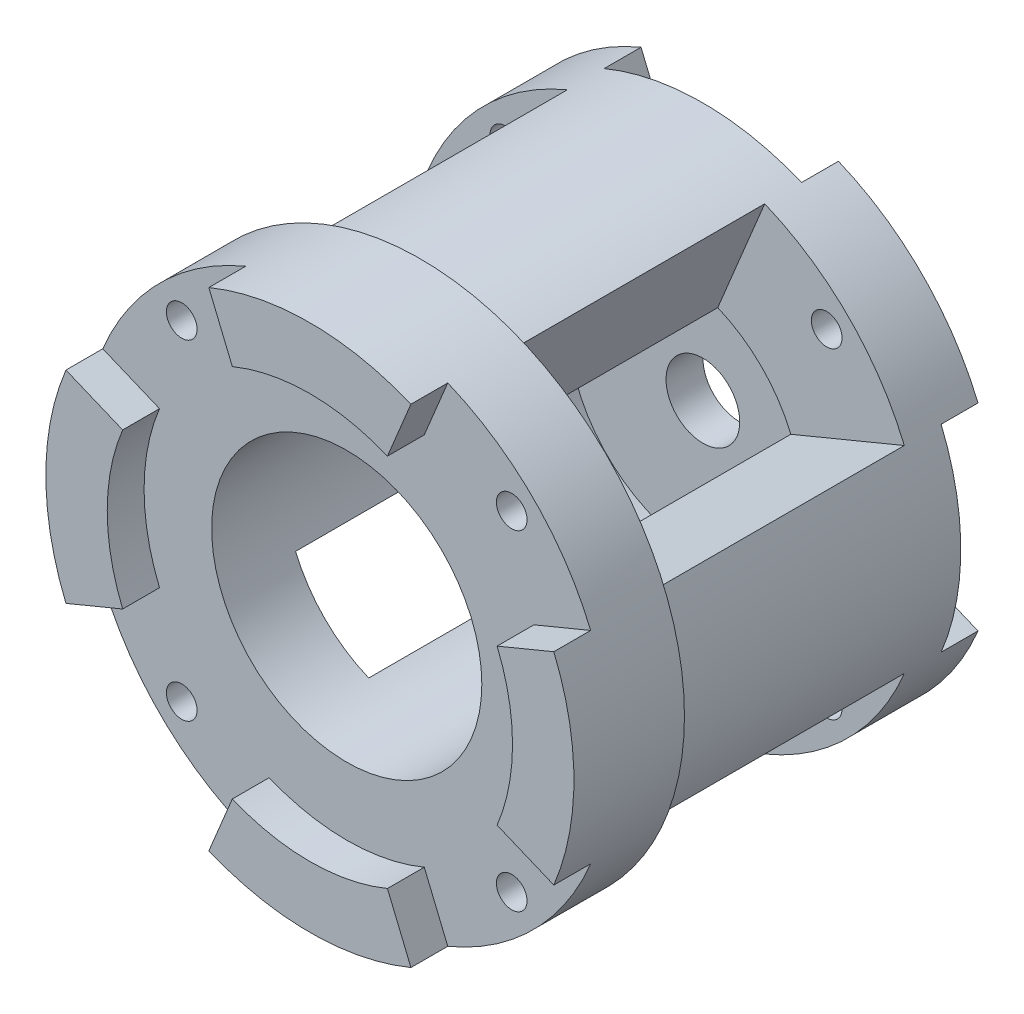
from build123d import *
from build123d.topology import SkipClean

# Parameters (mm, degrees)
SKETCH1_R           = 21
SKETCH1_R_2         = 1.25
SKETCH1_R_3         = 11
BOSS_EXTRUDE1_DEPTH = 3
BOSS_EXTRUDE2_START = -3
SKETCH1_3_R         = 3
SKETCH1_3_R_2       = 1.25
BOSS_EXTRUDE2_DEPTH = 3
BOSS_EXTRUDE3_DEPTH = 20
SKETCH5_R           = 21.5
SKETCH5_R_2         = 11
SKETCH5_R_3         = 1.25
BOSS_EXTRUDE4_DEPTH = 6
BOSS_EXTRUDE5_DEPTH = 3


with BuildPart() as part:
    # Sketch1 → Boss-Extrude1 (new body)
    with BuildSketch(Plane.XY):
        Circle(SKETCH1_R)
        with Locations((-13.081475452, -13.081475452)):
            Circle(SKETCH1_R_2, mode=Mode.SUBTRACT)
        with Locations((13.081475452, -13.081475452)):
            Circle(SKETCH1_R_2, mode=Mode.SUBTRACT)
        with Locations((-13.081475452, 13.081475452)):
            Circle(SKETCH1_R_2, mode=Mode.SUBTRACT)
        Circle(SKETCH1_R_3, mode=Mode.SUBTRACT)
        with Locations((13.081475452, 13.081475452)):
            Circle(SKETCH1_R_2, mode=Mode.SUBTRACT)
    extrude(amount=BOSS_EXTRUDE1_DEPTH)

    # Sketch1_3 → Boss-Extrude2 (add)
    with BuildSketch(Plane.XY.offset(BOSS_EXTRUDE2_START)):
        with BuildLine():
            ThreePointArc((0, 16), (-3.121445152, 15.692564486), (-6.122934918, 14.78207252))
            Line((-6.122934918, 14.78207252), (-8.03635208, 19.401470183))
            ThreePointArc((-8.03635208, 19.401470183), (-14.849242405, 14.849242405), (-19.401470183, 8.03635208))
            Line((-19.401470183, 8.03635208), (-14.78207252, 6.122934918))
            ThreePointArc((-14.78207252, 6.122934918), (-16, 0), (-14.78207252, -6.122934918))
            Line((-14.78207252, -6.122934918), (-19.401470183, -8.03635208))
            ThreePointArc((-19.401470183, -8.03635208), (-14.849242405, -14.849242405), (-8.03635208, -19.401470183))
            Line((-8.03635208, -19.401470183), (-6.122934918, -14.78207252))
            ThreePointArc((-6.122934918, -14.78207252), (0, -16), (6.122934918, -14.78207252))
            Line((6.122934918, -14.78207252), (8.03635208, -19.401470183))
            ThreePointArc((8.03635208, -19.401470183), (14.849242405, -14.849242405), (19.401470183, -8.03635208))
            Line((19.401470183, -8.03635208), (14.78207252, -6.122934918))
            ThreePointArc((14.78207252, -6.122934918), (16, 0), (14.78207252, 6.122934918))
            Line((14.78207252, 6.122934918), (19.401470183, 8.03635208))
            ThreePointArc((19.401470183, 8.03635208), (14.849242405, 14.849242405), (8.03635208, 19.401470183))
            Line((8.03635208, 19.401470183), (6.122934918, 14.78207252))
            ThreePointArc((6.122934918, 14.78207252), (3.121445152, 15.692564486), (0, 16))
        make_face()
        Circle(SKETCH1_3_R, mode=Mode.SUBTRACT)
        with Locations((-13.081475452, -13.081475452)):
            Circle(SKETCH1_3_R_2, mode=Mode.SUBTRACT)
        with Locations((13.081475452, -13.081475452)):
            Circle(SKETCH1_3_R_2, mode=Mode.SUBTRACT)
        with Locations((-13.081475452, 13.081475452)):
            Circle(SKETCH1_3_R_2, mode=Mode.SUBTRACT)
        with Locations((13.081475452, 13.081475452)):
            Circle(SKETCH1_3_R_2, mode=Mode.SUBTRACT)
    extrude(amount=BOSS_EXTRUDE2_DEPTH)

    # Sketch2 → Boss-Extrude3 (add)
    with SkipClean():  # the faces are left unmerged after this step: merging them gives an invalid solid
        with BuildSketch(Plane.XY.offset(3)):
            with BuildLine():
                Line((-10.162674858, 4.209517756), (-19.401470183, 8.03635208))
                ThreePointArc((-19.401470183, 8.03635208), (-21, 0), (-19.401470183, -8.03635208))
                Line((-19.401470183, -8.03635208), (-10.162674858, -4.209517756))
                ThreePointArc((-10.162674858, -4.209517756), (-11, 0), (-10.162674858, 4.209517756))
            make_face()
            with BuildLine():
                ThreePointArc((8.03635208, 19.401470183), (0, 21), (-8.03635208, 19.401470183))
                Line((-8.03635208, 19.401470183), (-4.209517756, 10.162674858))
                ThreePointArc((-4.209517756, 10.162674858), (0, 11), (4.209517756, 10.162674858))
                Line((4.209517756, 10.162674858), (8.03635208, 19.401470183))
            make_face()
            with BuildLine():
                Line((-4.209517756, -10.162674858), (-8.03635208, -19.401470183))
                ThreePointArc((-8.03635208, -19.401470183), (0, -21), (8.03635208, -19.401470183))
                Line((8.03635208, -19.401470183), (4.209517756, -10.162674858))
                ThreePointArc((4.209517756, -10.162674858), (0, -11), (-4.209517756, -10.162674858))
            make_face()
            with BuildLine():
                ThreePointArc((19.401470183, -8.03635208), (21, 0), (19.401470183, 8.03635208))
                Line((19.401470183, 8.03635208), (10.162674858, 4.209517756))
                ThreePointArc((10.162674858, 4.209517756), (11, 0), (10.162674858, -4.209517756))
                Line((10.162674858, -4.209517756), (19.401470183, -8.03635208))
            make_face()
        extrude(amount=BOSS_EXTRUDE3_DEPTH)

    # Sketch5 → Boss-Extrude4 (add)
    with SkipClean():  # the faces are left unmerged after this step: merging them gives an invalid solid
        with BuildSketch(Plane.XY.offset(23)):
            Circle(SKETCH5_R)
            Circle(SKETCH5_R_2, mode=Mode.SUBTRACT)
            with Locations((-13.435028843, 13.435028843)):
                Circle(SKETCH5_R_3, mode=Mode.SUBTRACT)
            with Locations((13.435028843, 13.435028843)):
                Circle(SKETCH5_R_3, mode=Mode.SUBTRACT)
            with Locations((13.435028843, -13.435028843)):
                Circle(SKETCH5_R_3, mode=Mode.SUBTRACT)
            with Locations((-13.435028843, -13.435028843)):
                Circle(SKETCH5_R_3, mode=Mode.SUBTRACT)
        extrude(amount=BOSS_EXTRUDE4_DEPTH)

    # Sketch6 → Boss-Extrude5 (add)
    with SkipClean():  # the faces are left unmerged after this step: merging them gives an invalid solid
        with BuildSketch(Plane.XY.offset(29)):
            with BuildLine():
                ThreePointArc((-15.244012286, -6.314276634), (-16.5, 0), (-15.244012286, 6.314276634))
                Line((-15.244012286, 6.314276634), (-19.863409949, 8.227693796))
                ThreePointArc((-19.863409949, 8.227693796), (-21.5, 0), (-19.863409949, -8.227693796))
                Line((-19.863409949, -8.227693796), (-15.244012286, -6.314276634))
            make_face()
            with BuildLine():
                Line((-8.227693796, 19.863409949), (-6.314276634, 15.244012286))
                ThreePointArc((-6.314276634, 15.244012286), (0, 16.5), (6.314276634, 15.244012286))
                Line((6.314276634, 15.244012286), (8.227693796, 19.863409949))
                ThreePointArc((8.227693796, 19.863409949), (0, 21.5), (-8.227693796, 19.863409949))
            make_face()
            with BuildLine():
                ThreePointArc((6.314276634, -15.244012286), (0, -16.5), (-6.314276634, -15.244012286))
                Line((-6.314276634, -15.244012286), (-8.227693796, -19.863409949))
                ThreePointArc((-8.227693796, -19.863409949), (0, -21.5), (8.227693796, -19.863409949))
                Line((8.227693796, -19.863409949), (6.314276634, -15.244012286))
            make_face()
            with BuildLine():
                Line((19.863409949, 8.227693796), (15.244012286, 6.314276634))
                ThreePointArc((15.244012286, 6.314276634), (16.5, 0), (15.244012286, -6.314276634))
                Line((15.244012286, -6.314276634), (19.863409949, -8.227693796))
                ThreePointArc((19.863409949, -8.227693796), (21.5, 0), (19.863409949, 8.227693796))
            make_face()
        extrude(amount=BOSS_EXTRUDE5_DEPTH)


solid = part.part
